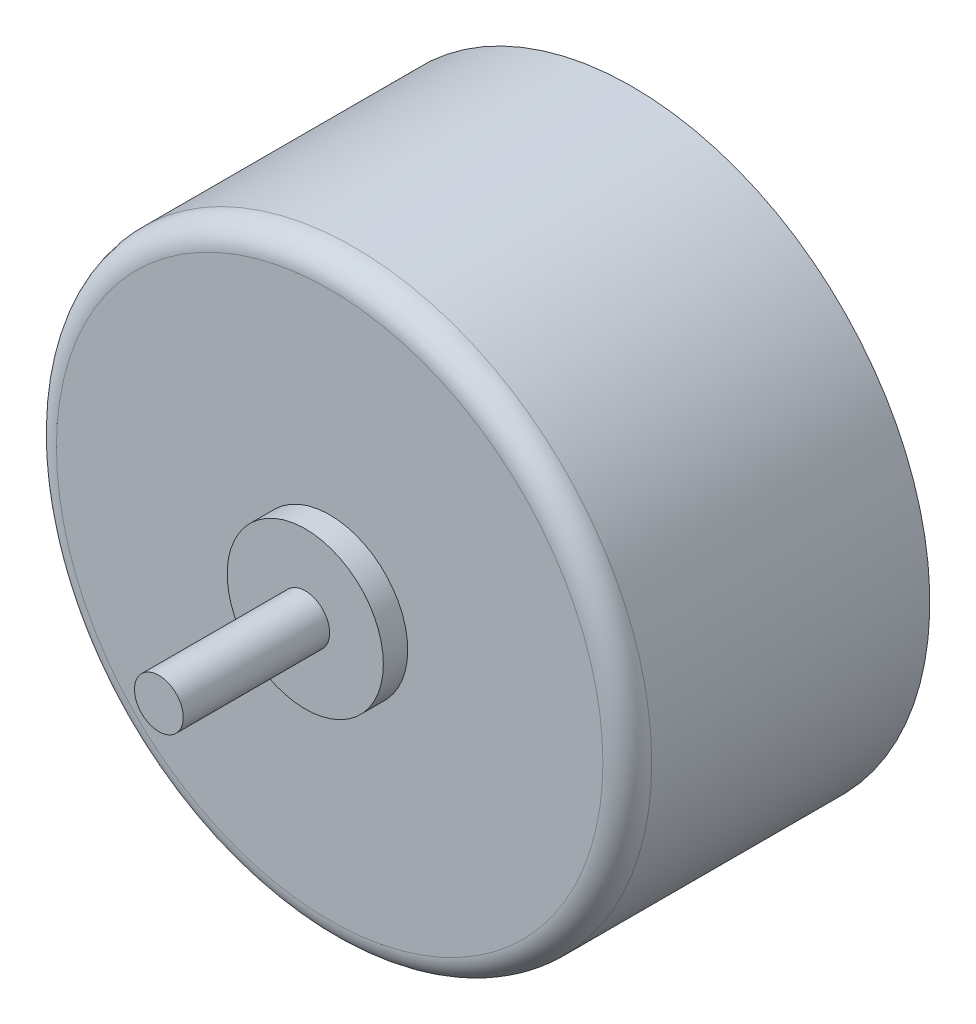
from build123d import *

# Parameters (mm, degrees)
SKETCH1_R           = 12.2
BOSS_EXTRUDE1_DEPTH = 12.4
SKETCH2_R           = 1
BOSS_EXTRUDE2_DEPTH = 7
SKETCH3_R           = 3.2
BOSS_EXTRUDE3_DEPTH = 1
SKETCH4_W           = 4
SKETCH4_H           = 4
SKETCH4_R           = 0.75
BOSS_EXTRUDE4_DEPTH = 12.5
FILLET1_R           = 1


with BuildPart() as part:
    # Sketch1 → Boss-Extrude1 (new body)
    with BuildSketch(Plane.XY):
        Circle(SKETCH1_R)
    extrude(amount=BOSS_EXTRUDE1_DEPTH)

    # Sketch2 → Boss-Extrude2 (add)
    with BuildSketch(Plane.XY.offset(12.4)):
        Circle(SKETCH2_R)
    extrude(amount=BOSS_EXTRUDE2_DEPTH)

    # Sketch3 → Boss-Extrude3 (add)
    with BuildSketch(Plane.XY.offset(12.4)):
        Circle(SKETCH3_R)
    extrude(amount=BOSS_EXTRUDE3_DEPTH)

    # Sketch4 → Boss-Extrude4 (add)
    with BuildSketch(Plane(origin=(0, 0, 0), x_dir=(0, 0, -1), z_dir=(1, 0, 0))):
        with Locations((-2, 0)):
            Rectangle(SKETCH4_W, SKETCH4_H)
        with Locations((-3, 1)):
            Circle(SKETCH4_R, mode=Mode.SUBTRACT)
        with Locations((-3, -1)):
            Circle(SKETCH4_R, mode=Mode.SUBTRACT)
    extrude(amount=-BOSS_EXTRUDE4_DEPTH)

    # Fillet1
    fillet1_edges = [part.edges().sort_by_distance(p)[0] for p in [
        (-12.2, 0, 12.4),
    ]]
    fillet(fillet1_edges, radius=FILLET1_R)


solid = part.part
